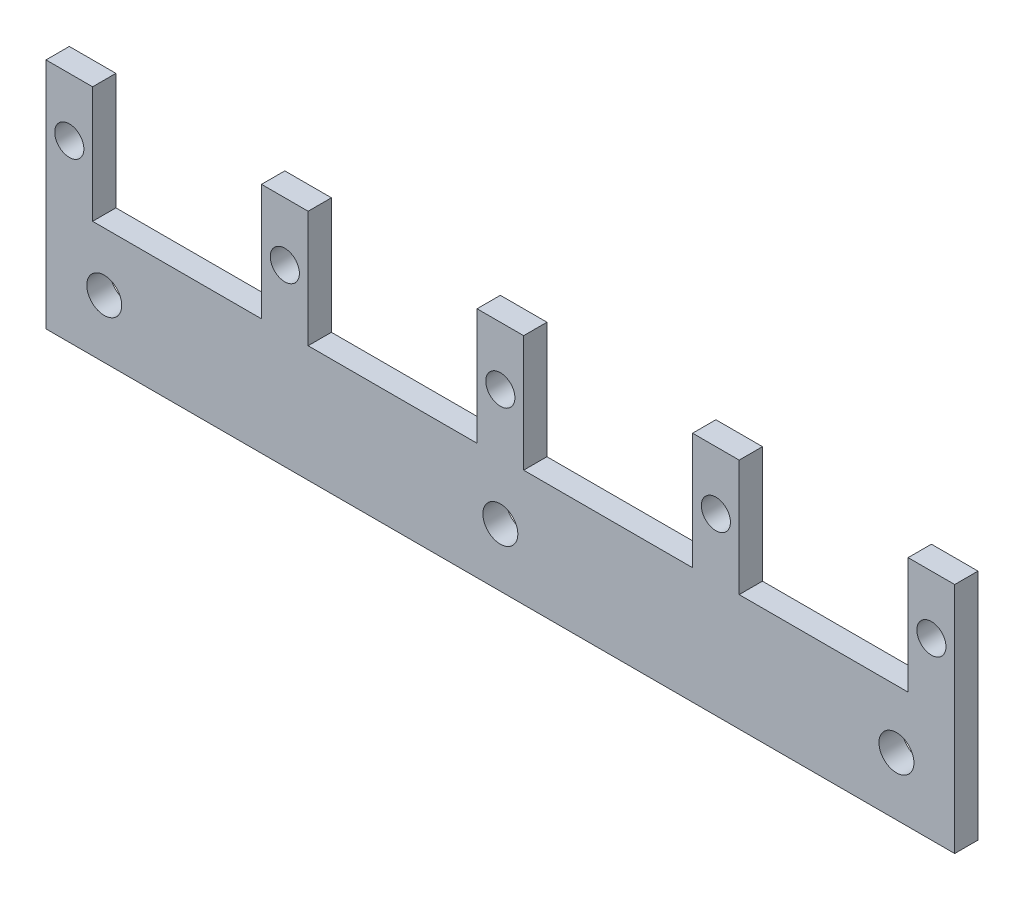
from build123d import *

# Parameters (mm, degrees)
SKETCH1_W           = 156
SKETCH1_H           = 20
SKETCH1_W_2         = 8
BOSS_EXTRUDE1_DEPTH = 2
SKETCH2_R           = 2.5
CUT_EXTRUDE1_DEPTH  = 111.92580296
LPATTERN1_COUNT     = 5
LPATTERN1_PITCH     = 37
SKETCH3_R           = 3
CUT_EXTRUDE2_DEPTH  = 111.92580296


with BuildPart() as part:
    # Sketch1 → Boss-Extrude1 (new, symmetric)
    with BuildSketch(Plane.XY):
        with Locations((28, 2.442776735)):
            Rectangle(SKETCH1_W, SKETCH1_H)
        with Locations((102, 22.442776735)):
            Rectangle(SKETCH1_W_2, SKETCH1_H)
        with Locations((65, 22.442776735)):
            Rectangle(SKETCH1_W_2, SKETCH1_H)
        with Locations((28, 22.442776735)):
            Rectangle(SKETCH1_W_2, SKETCH1_H)
        with Locations((-9, 22.442776735)):
            Rectangle(SKETCH1_W_2, SKETCH1_H)
        with Locations((-46, 22.442776735)):
            Rectangle(SKETCH1_W_2, SKETCH1_H)
    extrude(amount=BOSS_EXTRUDE1_DEPTH, both=True)

    # Sketch2 → Cut-Extrude1 (cut, through all)
    with BuildSketch(Plane.XY.offset(2)):
        with Locations((-46, 22.442776735)):
            Circle(SKETCH2_R)
    cut_extrude1 = extrude(amount=-CUT_EXTRUDE1_DEPTH, mode=Mode.SUBTRACT)

    # LPattern1: Cut-Extrude1 ×5
    with Locations(*[(i * LPATTERN1_PITCH, 0, 0) for i in range(1, LPATTERN1_COUNT)]):
        add(cut_extrude1, mode=Mode.SUBTRACT)

    # Sketch3 → Cut-Extrude2 (cut, through all)
    with BuildSketch(Plane.XY.offset(2)):
        with Locations((28, 2.442776735)):
            Circle(SKETCH3_R)
        with Locations((96, 2.442776735)):
            Circle(SKETCH3_R)
        with Locations((-40, 2.442776735)):
            Circle(SKETCH3_R)
    extrude(amount=-CUT_EXTRUDE2_DEPTH, mode=Mode.SUBTRACT)


solid = part.part
